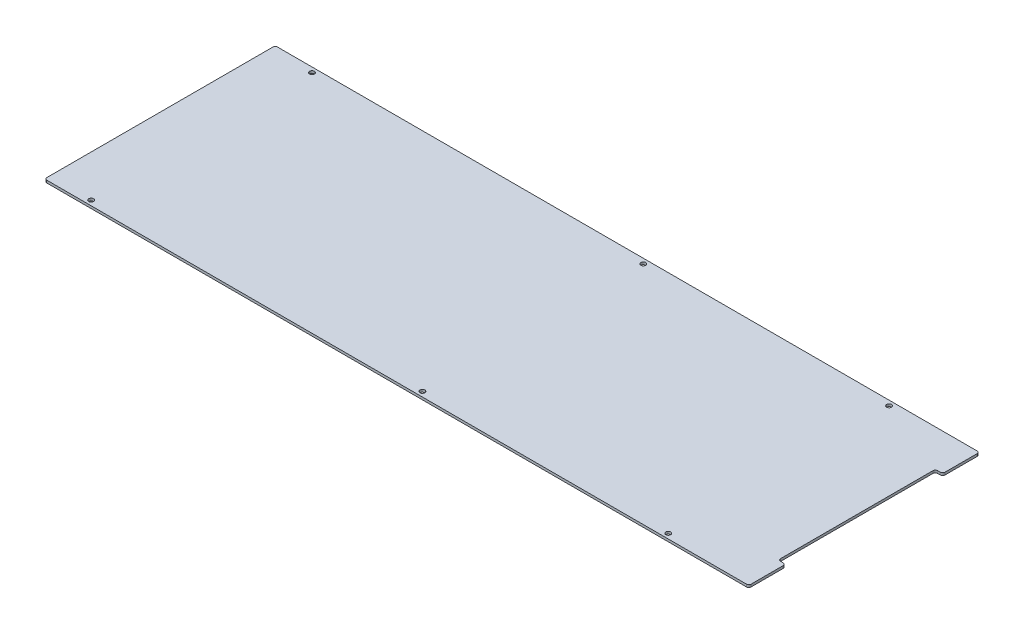
from build123d import *

# Parameters (mm, degrees)
SKETCH1_W                   = 911.225
SKETCH1_H                   = 298.45
BOSS_EXTRUDE1_DEPTH         = 3.175
SKETCH2_W                   = 9.525
SKETCH2_H                   = 203.2
CUT_EXTRUDE1_DEPTH          = 4.175
FILLET1_R                   = 3.175
F_1_4_0_25_DIAMETER_HOLE1_D = 6.35
FILLET2_R                   = 3.175


with BuildPart() as part:
    # Sketch1 → Boss-Extrude1 (new body)
    with BuildSketch(Plane(origin=(0, 0, 0), x_dir=(1, 0, 0), z_dir=(0, 1, 0))):
        Rectangle(SKETCH1_W, SKETCH1_H)
    extrude(amount=BOSS_EXTRUDE1_DEPTH)

    # Sketch2 → Cut-Extrude1 (cut, through all)
    with BuildSketch(Plane(origin=(0, 3.175, 0), x_dir=(1, 0, 0), z_dir=(0, 1, 0))):
        with Locations((450.85, 0)):
            Rectangle(SKETCH2_W, SKETCH2_H)
    extrude(amount=-CUT_EXTRUDE1_DEPTH, mode=Mode.SUBTRACT)

    # Fillet1
    fillet1_edges = [part.edges().sort_by_distance(p)[0] for p in [
        (446.0875, 1.5875, 101.6),
        (446.0875, 1.5875, -101.6),
    ]]
    fillet(fillet1_edges, radius=FILLET1_R)

    # 1/4 (0.25) Diameter Hole1 (through all)
    with Locations(Plane(origin=(0, 0, 0), x_dir=(-1, 0, 0), z_dir=(0, -1, 0))):
        with Locations((-345.04884, 142.875), (401.6375, 142.875), (-26.9875, 142.875)):
            f_1_4_0_25_diameter_hole1 = Hole(F_1_4_0_25_DIAMETER_HOLE1_D / 2)

    # Mirror1: 1/4 (0.25) Diameter Hole1 across plane
    add(f_1_4_0_25_diameter_hole1.mirror(Plane.XY), mode=Mode.SUBTRACT)

    # Fillet2
    fillet2_edges = [part.edges().sort_by_distance(p)[0] for p in [
        (455.6125, 1.5875, -101.6),
        (455.6125, 1.5875, 101.6),
        (455.6125, 1.5875, 149.225),
        (-455.6125, 1.5875, 149.225),
        (-455.6125, 1.5875, -149.225),
        (455.6125, 1.5875, -149.225),
    ]]
    fillet(fillet2_edges, radius=FILLET2_R)


solid = part.part
